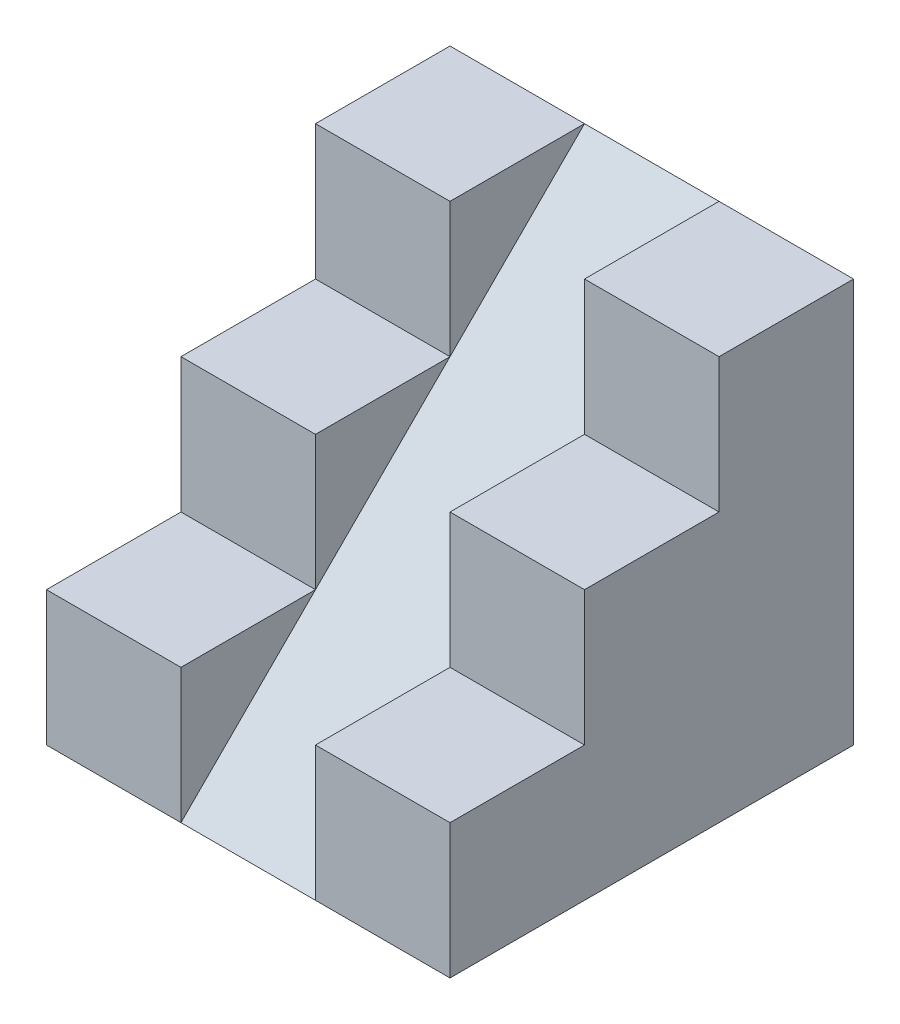
from build123d import *

# Parameters (mm, degrees)
CROQUIS4_W              = 60
CROQUIS4_H              = 60
SALIENTE_EXTRUIR1_DEPTH = 60
CROQUIS10_W             = 20
CROQUIS10_H             = 20
CORTAR_EXTRUIR6_DEPTH   = 60
CROQUIS11_W             = 20
CROQUIS11_H             = 20
CORTAR_EXTRUIR7_DEPTH   = 20
SALIENTE_EXTRUIR2_DEPTH = 20
CROQUIS13_W             = 20
CROQUIS13_H             = 20
CORTAR_EXTRUIR8_DEPTH   = 20
SALIENTE_EXTRUIR3_DEPTH = 20
CORTAR_EXTRUIR9_START   = -40
CORTAR_EXTRUIR9_DEPTH   = 20


with BuildPart() as part:
    # Croquis4 → Saliente-Extruir1 (new body)
    with BuildSketch(Plane.XY):
        with Locations((30, 30)):
            Rectangle(CROQUIS4_W, CROQUIS4_H)
    extrude(amount=SALIENTE_EXTRUIR1_DEPTH)

    # Croquis10 → Cortar-Extruir6 (cut)
    with BuildSketch(Plane(origin=(60, 0, 0), x_dir=(0, 0, -1), z_dir=(1, 0, 0))):
        with Locations((-30, 50)):
            Rectangle(CROQUIS10_W, CROQUIS10_H)
        with Locations((-50, 50)):
            Rectangle(CROQUIS10_W, CROQUIS10_H)
        with Locations((-50, 30)):
            Rectangle(CROQUIS10_W, CROQUIS10_H)
    extrude(amount=-CORTAR_EXTRUIR6_DEPTH, mode=Mode.SUBTRACT)

    # Croquis11 → Cortar-Extruir7 (cut)
    with BuildSketch(Plane(origin=(0, 60, 0), x_dir=(1, 0, 0), z_dir=(0, 1, 0))):
        with Locations((30, -10)):
            Rectangle(CROQUIS11_W, CROQUIS11_H)
    extrude(amount=-CORTAR_EXTRUIR7_DEPTH, mode=Mode.SUBTRACT)

    # Croquis12 → Saliente-Extruir2 (add)
    with BuildSketch(Plane(origin=(20, 0, 0), x_dir=(0, 0, -1), z_dir=(1, 0, 0))):
        Polygon((0, 60), (0, 40), (-20, 40), align=None)
    extrude(amount=SALIENTE_EXTRUIR2_DEPTH)

    # Croquis13 → Cortar-Extruir8 (cut)
    with BuildSketch(Plane(origin=(0, 40, 0), x_dir=(1, 0, 0), z_dir=(0, 1, 0))):
        with Locations((30, -30)):
            Rectangle(CROQUIS13_W, CROQUIS13_H)
    extrude(amount=-CORTAR_EXTRUIR8_DEPTH, mode=Mode.SUBTRACT)

    # Croquis14 → Saliente-Extruir3 (add)
    with BuildSketch(Plane(origin=(20, 0, 0), x_dir=(0, 0, -1), z_dir=(1, 0, 0))):
        Polygon((-20, 40), (-40, 20), (-20, 20), align=None)
    extrude(amount=SALIENTE_EXTRUIR3_DEPTH)

    # Croquis16 → Cortar-Extruir9 (cut)
    with BuildSketch(Plane(origin=(60, 0, 0), x_dir=(0, 0, -1), z_dir=(1, 0, 0)).offset(CORTAR_EXTRUIR9_START)):
        Polygon((-40, 20), (-60, 0), (-60, 20), align=None)
    extrude(amount=CORTAR_EXTRUIR9_DEPTH, mode=Mode.SUBTRACT)


solid = part.part
